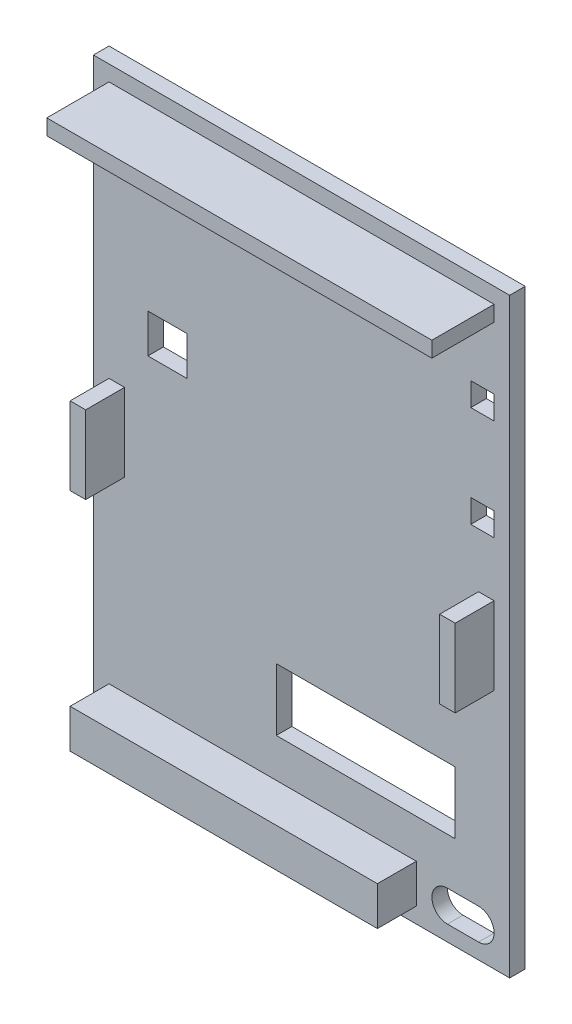
from build123d import *

# Parameters (mm, degrees)
SKETCH1_W           = 53.5
SKETCH1_H           = 76
BOSS_EXTRUDE1_DEPTH = 2
SKETCH5_W           = 49.5
SKETCH5_H           = 2
BOSS_EXTRUDE2_DEPTH = 8
SKETCH6_W           = 2
SKETCH6_H           = 10
BOSS_EXTRUDE3_DEPTH = 5
SKETCH7_W           = 39.5
SKETCH7_H           = 5
BOSS_EXTRUDE4_DEPTH = 5
SKETCH9_W           = 1.709615385
SKETCH9_H           = 9.525
CUT_EXTRUDE1_DEPTH  = 1.5
SKETCH10_W          = 23
SKETCH10_H          = 8
SKETCH10_W_2        = 5
SKETCH10_H_2        = 5
SKETCH10_W_3        = 3
SKETCH10_H_3        = 3
CUT_EXTRUDE2_DEPTH  = 3
CUT_EXTRUDE3_DEPTH  = 10


with BuildPart() as part:
    # Sketch1 → Boss-Extrude1 (new body)
    with BuildSketch(Plane.XY):
        with Locations((-27.675806452, -6.092473118)):
            Rectangle(SKETCH1_W, SKETCH1_H)
    extrude(amount=BOSS_EXTRUDE1_DEPTH)

    # Sketch5 → Boss-Extrude2 (add)
    with BuildSketch(Plane.XY.offset(2)):
        with Locations((-27.675806452, 28.907526882)):
            Rectangle(SKETCH5_W, SKETCH5_H)
    extrude(amount=BOSS_EXTRUDE2_DEPTH)

    # Sketch6 → Boss-Extrude3 (add)
    with BuildSketch(Plane.XY.offset(2)):
        with Locations((-3.925806452, -8.092473118)):
            Rectangle(SKETCH6_W, SKETCH6_H)
        with Locations((-51.425806452, -8.092473118)):
            Rectangle(SKETCH6_W, SKETCH6_H)
    extrude(amount=BOSS_EXTRUDE3_DEPTH)

    # Sketch7 → Boss-Extrude4 (add)
    with BuildSketch(Plane.XY.offset(2)):
        with Locations((-32.675806452, -39.592473118)):
            Rectangle(SKETCH7_W, SKETCH7_H)
    extrude(amount=BOSS_EXTRUDE4_DEPTH)

    # Sketch9 → Cut-Extrude1 (cut)
    with BuildSketch(Plane(origin=(0, 0, 0), x_dir=(-1, 0, 0), z_dir=(0, 0, -1))):
        with BuildLine():
            Line((15.219559537, -13.308202679), (13.311506652, -13.308202679))
            add(Edge.make_bspline(
                [(13.311506652, -13.308202679), (13.186836951, -13.307644632), (12.946322965, -13.306568042), (12.599482023, -13.293512922), (12.279504227, -13.270117417), (11.986463285, -13.241204079), (11.720479059, -13.20066936), (11.481220492, -13.154197474), (11.268631399, -13.097587727), (11.080335525, -13.030371915), (10.911293942, -12.951196416), (10.751514042, -12.866628214), (10.603400621, -12.766385704), (10.463476399, -12.657694562), (10.332799832, -12.538293565), (10.21040258, -12.408654612), (10.097544997, -12.266893671), (9.994934626, -12.113987348), (9.901800068, -11.953048709), (9.820445025, -11.783710745), (9.754450916, -11.605727062), (9.699091034, -11.420243182), (9.654625179, -11.22726879), (9.625027353, -11.025616635), (9.604923003, -10.81669485), (9.603149073, -10.674502546), (9.602251844, -10.602583689)],
                knots=[0, 0, 0, 0, 0.000373998, 0.00072152, 0.001040987, 0.001336408, 0.001604638, 0.001847867, 0.00206726, 0.002264021, 0.002446727, 0.002626874, 0.002805743, 0.002982462, 0.003158044, 0.00333622, 0.003516801, 0.003700965, 0.003888168, 0.00407422, 0.00426382, 0.004456995, 0.004654642, 0.004857301, 0.005068052, 0.005283738, 0.005283738, 0.005283738, 0.005283738], degree=3))
            add(Edge.make_bspline(
                [(9.602251844, -10.602583689), (9.603544395, -10.523019265), (9.606084416, -10.366665396), (9.631172931, -10.13750909), (9.673608769, -9.918880593), (9.730418474, -9.709845921), (9.804518816, -9.51086238), (9.897391347, -9.323237133), (10.003624799, -9.144619098), (10.129037616, -8.978275216), (10.267619176, -8.823358722), (10.416839841, -8.678183737), (10.581177045, -8.548717219), (10.754765087, -8.428228365), (10.942570804, -8.323789375), (11.139029875, -8.227083225), (11.349125061, -8.145019198), (11.495329379, -8.101965715), (11.569454368, -8.080137776)],
                knots=[0, 0, 0, 0, 0.000238629, 0.000468935, 0.000690466, 0.000906177, 0.001118109, 0.001326323, 0.001533459, 0.001740673, 0.001950151, 0.002156618, 0.002364316, 0.00257707, 0.002789833, 0.003008294, 0.003233647, 0.003465395, 0.003465395, 0.003465395, 0.003465395], degree=3))
            add(Edge.make_bspline(
                [(11.569454368, -8.080137776), (11.618282841, -8.067989173), (11.724061036, -8.041671386), (11.899094896, -8.014952228), (12.100803042, -7.990385604), (12.329837728, -7.969273566), (12.586330998, -7.954922299), (12.8700345, -7.943714597), (13.181076804, -7.935565441), (13.397363322, -7.935276273), (13.509944152, -7.935125756)],
                knots=[0, 0, 0, 0, 0.000150881, 0.000326857, 0.000530626, 0.000760552, 0.001016687, 0.001301217, 0.001612323, 0.001950054, 0.001950054, 0.001950054, 0.001950054], degree=3))
            Line((13.509944152, -7.935125756), (13.509944152, -3.783202679))
            Line((13.509944152, -3.783202679), (15.219559537, -3.783202679))
            Line((15.219559537, -3.783202679), (15.219559537, -13.308202679))
        make_face()
        with BuildLine():
            Line((13.509944152, -9.644741141), (12.905091387, -9.644741141))
            add(Edge.make_bspline(
                [(12.905091387, -9.644741141), (12.795027079, -9.645436425), (12.592507116, -9.646715757), (12.315961347, -9.665314329), (12.093650961, -9.693591456), (11.918214488, -9.734478435), (11.779637332, -9.795359255), (11.661555246, -9.868787837), (11.55664669, -9.95702559), (11.469197168, -10.062808911), (11.397934257, -10.180829428), (11.347951288, -10.3119783), (11.316404182, -10.454159631), (11.313408035, -10.553437066), (11.311867229, -10.604491742)],
                knots=[0, 0, 0, 0, 0.000330143, 0.000607468, 0.000830897, 0.001002123, 0.001145684, 0.001282812, 0.001418163, 0.001554972, 0.001692735, 0.001829863, 0.001974322, 0.002127264, 0.002127264, 0.002127264, 0.002127264], degree=3))
            add(Edge.make_bspline(
                [(11.311867229, -10.604491742), (11.313359987, -10.649108701), (11.316256296, -10.73567633), (11.337826606, -10.860527016), (11.371304826, -10.976685342), (11.422469792, -11.082532093), (11.484588722, -11.18053605), (11.563394312, -11.267646324), (11.654273353, -11.346681228), (11.724553857, -11.38846297), (11.760259657, -11.409690059)],
                knots=[0, 0, 0, 0, 0.000133782, 0.000259568, 0.000379092, 0.00049517, 0.000611076, 0.000725956, 0.000846405, 0.000970795, 0.000970795, 0.000970795, 0.000970795], degree=3))
            add(Edge.make_bspline(
                [(11.760259657, -11.409690059), (11.790496888, -11.424981894), (11.854515302, -11.457357842), (11.963544867, -11.494997248), (12.089363321, -11.526750234), (12.23282008, -11.553104905), (12.393342852, -11.573558867), (12.570903, -11.589201032), (12.765761818, -11.595491355), (12.901274466, -11.597526851), (12.971873238, -11.598587295)],
                knots=[0, 0, 0, 0, 0.000101558, 0.000215019, 0.000345061, 0.000490637, 0.000652281, 0.000830386, 0.001025157, 0.001236985, 0.001236985, 0.001236985, 0.001236985], degree=3))
            Line((12.971873238, -11.598587295), (13.509944152, -11.598587295))
            Line((13.509944152, -11.598587295), (13.509944152, -9.644741141))
        make_face(mode=Mode.SUBTRACT)
        with BuildLine():
            add(Edge.make_bspline(
                [(29.060575162, -13.552433449), (28.894970537, -13.548147393), (28.568029499, -13.539685747), (28.087231524, -13.469098141), (27.623838209, -13.354218133), (27.177783129, -13.193864141), (26.75058755, -12.986191342), (26.340681847, -12.734036176), (25.949189323, -12.435259008), (25.58067439, -12.094123397), (25.242755218, -11.721102279), (24.945720426, -11.32340803), (24.693575539, -10.905146674), (24.488908925, -10.466236718), (24.32907906, -10.007281052), (24.217999184, -9.528105499), (24.146377513, -9.029323667), (24.138159335, -8.689692508), (24.133982613, -8.517081886)],
                knots=[0, 0, 0, 0, 0.000496622, 0.000980444, 0.001454322, 0.001926907, 0.002399677, 0.002876804, 0.003368331, 0.003874684, 0.004381282, 0.004876233, 0.005361513, 0.005843802, 0.006326543, 0.00681666, 0.007317486, 0.007835075, 0.007835075, 0.007835075, 0.007835075], degree=3))
            add(Edge.make_bspline(
                [(24.133982613, -8.517081886), (24.138432046, -8.346416515), (24.147199796, -8.010114926), (24.215066612, -7.515924886), (24.32807709, -7.041899501), (24.484825626, -6.587876715), (24.685913603, -6.153849087), (24.934207751, -5.741224985), (25.228076768, -5.349156592), (25.561517743, -4.980045872), (25.926342619, -4.642823837), (26.315056928, -4.346784314), (26.724049314, -4.097787747), (27.150706661, -3.891115253), (27.599053996, -3.735806755), (28.064120527, -3.619557884), (28.54979667, -3.552336385), (28.879743891, -3.543471537), (29.047218791, -3.53897191)],
                knots=[0, 0, 0, 0, 0.000511871, 0.001008657, 0.001493205, 0.001971716, 0.002447204, 0.002925612, 0.003413693, 0.003914901, 0.004415862, 0.004902041, 0.005378172, 0.005850114, 0.006321418, 0.006799, 0.007286334, 0.007788674, 0.007788674, 0.007788674, 0.007788674], degree=3))
            add(Edge.make_bspline(
                [(29.047218791, -3.53897191), (29.222391013, -3.542960978), (29.566580485, -3.550798952), (30.070428355, -3.624705737), (30.552470158, -3.737386473), (31.011385087, -3.900521067), (31.446816387, -4.112491759), (31.860716783, -4.368430194), (32.249973376, -4.673280172), (32.61328866, -5.017846903), (32.942414844, -5.394976258), (33.232943282, -5.793354604), (33.478007948, -6.209969243), (33.677621431, -6.645007197), (33.834988517, -7.095766892), (33.945993157, -7.564993032), (34.011566238, -8.051560391), (34.020700188, -8.382046662), (34.025328767, -8.549518785)],
                knots=[0, 0, 0, 0, 0.000525214, 0.001031973, 0.001524388, 0.002008394, 0.002489697, 0.002974703, 0.003465532, 0.003970312, 0.004474692, 0.004965121, 0.005447477, 0.005922165, 0.006398873, 0.00687741, 0.007366378, 0.007868718, 0.007868718, 0.007868718, 0.007868718], degree=3))
            add(Edge.make_bspline(
                [(34.025328767, -8.549518785), (34.02385601, -8.662180378), (34.020929144, -8.886077008), (33.986446086, -9.21796651), (33.935303496, -9.542902272), (33.865290516, -9.861495327), (33.770959753, -10.172924637), (33.656308372, -10.477975767), (33.522703376, -10.776647031), (33.368633584, -11.066237369), (33.19434991, -11.343281989), (33.008261969, -11.610200616), (32.803242201, -11.859986107), (32.583522304, -12.095351747), (32.348241655, -12.315221627), (32.096990485, -12.520346506), (31.830164258, -12.710203203), (31.550649059, -12.886360588), (31.259401041, -13.040647088), (30.963349543, -13.180496505), (30.659652505, -13.293886373), (30.350514976, -13.387799433), (30.036647688, -13.463168477), (29.715627311, -13.513282466), (29.390163185, -13.548037944), (29.170698562, -13.550964803), (29.060575162, -13.552433449)],
                knots=[0, 0, 0, 0, 0.00033786, 0.000671442, 0.000999877, 0.001324386, 0.001649148, 0.001975196, 0.002301445, 0.002630079, 0.002958336, 0.003282845, 0.003605583, 0.003926873, 0.004248163, 0.004570901, 0.004899175, 0.005230061, 0.005561277, 0.005887376, 0.006211638, 0.006532747, 0.00685625, 0.007179033, 0.007506918, 0.007837149, 0.007837149, 0.007837149, 0.007837149], degree=3))
        make_face()
        with BuildLine():
            add(Edge.make_bspline(
                [(29.087287902, -11.842818064), (29.198739231, -11.839827571), (29.418699556, -11.833925534), (29.741341387, -11.788960104), (30.051088584, -11.71714492), (30.346225759, -11.613122503), (30.628025915, -11.480724801), (30.897011598, -11.320430447), (31.149370698, -11.126668225), (31.388804605, -10.910072313), (31.604364327, -10.667737749), (31.798181715, -10.410864472), (31.95489094, -10.133271679), (32.089638502, -9.844102526), (32.189170417, -9.536044231), (32.264953591, -9.214096556), (32.306230115, -8.874954478), (32.312507258, -8.644387139), (32.315713383, -8.526622151)],
                knots=[0, 0, 0, 0, 0.000334258, 0.000659691, 0.000975329, 0.00128671, 0.001596555, 0.001908077, 0.002224054, 0.002549549, 0.002875178, 0.003195737, 0.00351287, 0.003829641, 0.004151243, 0.004482179, 0.00482061, 0.005173929, 0.005173929, 0.005173929, 0.005173929], degree=3))
            add(Edge.make_bspline(
                [(32.315713383, -8.526622151), (32.311816181, -8.396075709), (32.304178312, -8.140226312), (32.251219159, -7.766800031), (32.1584244, -7.414541716), (32.031655578, -7.082272944), (31.863143653, -6.77348771), (31.661599587, -6.484442514), (31.421977156, -6.216930728), (31.237698387, -6.060616075), (31.144168912, -5.981279603)],
                knots=[0, 0, 0, 0, 0.000391616, 0.000767502, 0.001128488, 0.001482471, 0.00183165, 0.002181011, 0.0025377, 0.002905316, 0.002905316, 0.002905316, 0.002905316], degree=3))
            add(Edge.make_bspline(
                [(31.144168912, -5.981279603), (31.067530004, -5.922678157), (30.915978875, -5.806795567), (30.674070279, -5.658268256), (30.424952059, -5.530965533), (30.166744306, -5.428106439), (29.899992341, -5.347199205), (29.624732744, -5.290541199), (29.341355536, -5.254983401), (29.149722586, -5.25073357), (29.05294295, -5.248587295)],
                knots=[0, 0, 0, 0, 0.00028927, 0.000572022, 0.000850206, 0.001127636, 0.001404698, 0.001685357, 0.001969829, 0.002260079, 0.002260079, 0.002260079, 0.002260079], degree=3))
            add(Edge.make_bspline(
                [(29.05294295, -5.248587295), (28.943410149, -5.251607423), (28.727900919, -5.257549621), (28.411234966, -5.301900398), (28.108000086, -5.377286395), (27.815385612, -5.479657848), (27.537309869, -5.616853326), (27.269436477, -5.779762435), (27.014958025, -5.973465959), (26.776976767, -6.19552027), (26.558879667, -6.437866263), (26.365924428, -6.696128941), (26.206125681, -6.970318353), (26.072833186, -7.256771921), (25.968983489, -7.557770416), (25.897913434, -7.873336539), (25.852238071, -8.202197125), (25.846514037, -8.425976745), (25.843597998, -8.539978521)],
                knots=[0, 0, 0, 0, 0.00032854, 0.000646413, 0.000956933, 0.001264716, 0.001574485, 0.001885363, 0.002204014, 0.002532093, 0.002860417, 0.003180976, 0.003497419, 0.003810723, 0.004127512, 0.004450582, 0.004779797, 0.00512168, 0.00512168, 0.00512168, 0.00512168], degree=3))
            add(Edge.make_bspline(
                [(25.843597998, -8.539978521), (25.846603636, -8.653329432), (25.852519775, -8.876443414), (25.897119094, -9.204391702), (25.971263944, -9.518223893), (26.076054313, -9.818748968), (26.206601309, -10.107544661), (26.37059007, -10.382104472), (26.564466056, -10.64219086), (26.784685051, -10.886257576), (27.024340466, -11.11055429), (27.281644893, -11.305199235), (27.549386356, -11.474340497), (27.833711373, -11.606838693), (28.128802055, -11.712399789), (28.436459285, -11.790136478), (28.757848274, -11.83360966), (28.976495851, -11.839721236), (29.087287902, -11.842818064)],
                knots=[0, 0, 0, 0, 0.000339976, 0.000669191, 0.000990838, 0.001305823, 0.001622594, 0.001940009, 0.002263236, 0.002594255, 0.002925031, 0.003246355, 0.00356086, 0.003873245, 0.004185263, 0.004499947, 0.00482349, 0.005155842, 0.005155842, 0.005155842, 0.005155842], degree=3))
        make_face(mode=Mode.SUBTRACT)
        with Locations((44.038790306, -8.545702679)):
            Rectangle(SKETCH9_W, SKETCH9_H)
    extrude(amount=-CUT_EXTRUDE1_DEPTH, mode=Mode.SUBTRACT)

    # Sketch10 → Cut-Extrude2 (cut)
    with BuildSketch(Plane(origin=(0, 0, 0), x_dir=(-1, 0, 0), z_dir=(0, 0, -1))):
        with Locations((19.425806452, -28.092473118)):
            Rectangle(SKETCH10_W, SKETCH10_H)
        with Locations((44.925806452, 4.407526882)):
            Rectangle(SKETCH10_W_2, SKETCH10_H_2)
        with Locations((4.425806452, 5.407526882)):
            Rectangle(SKETCH10_W_3, SKETCH10_H_3)
        with Locations((4.425806452, 18.407526882)):
            Rectangle(SKETCH10_W_3, SKETCH10_H_3)
    extrude(amount=-CUT_EXTRUDE2_DEPTH, mode=Mode.SUBTRACT)

    # Sketch11 → Cut-Extrude3 (cut)
    with BuildSketch(Plane.XY.offset(2)):
        with BuildLine():
            Line((-4.925806452, -38.092473118), (-8.925806452, -38.092473118))
            ThreePointArc((-8.925806452, -38.092473118), (-10.925806452, -40.092473118), (-8.925806452, -42.092473118))
            Line((-8.925806452, -42.092473118), (-4.925806452, -42.092473118))
            ThreePointArc((-4.925806452, -42.092473118), (-2.925806452, -40.092473118), (-4.925806452, -38.092473118))
        make_face()
    extrude(amount=-CUT_EXTRUDE3_DEPTH, mode=Mode.SUBTRACT)


solid = part.part
